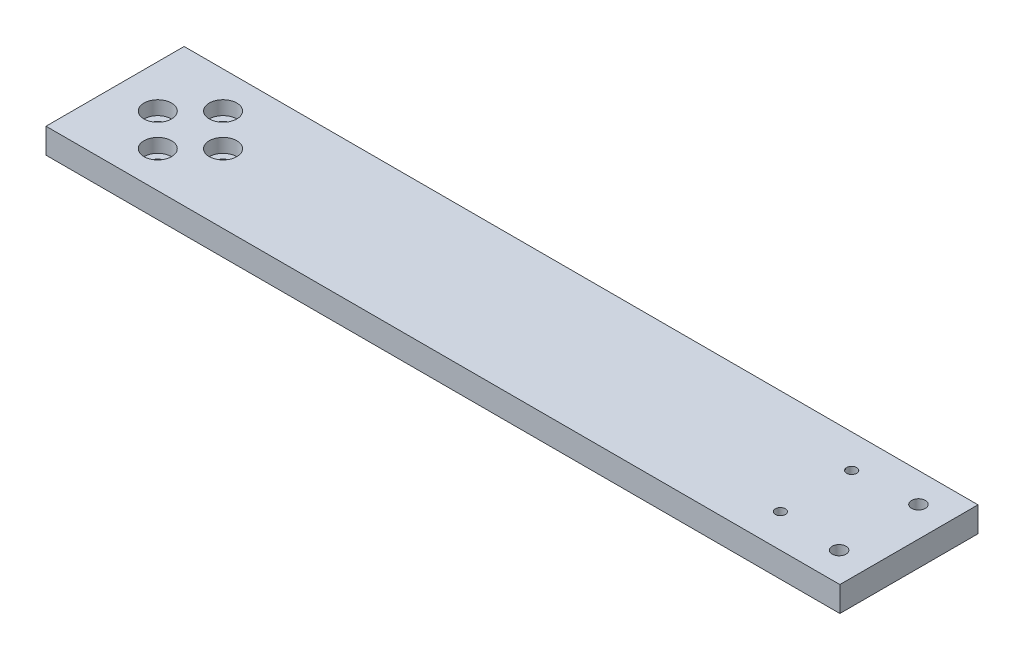
from build123d import *

# Parameters (mm, degrees)
SKETCH1_W           = 316.1
SKETCH1_H           = 55
BOSS_EXTRUDE1_DEPTH = 10
SKETCH2_R           = 2
SKETCH2_R_2         = 2.75
CUT_EXTRUDE1_DEPTH  = 11
SKETCH3_R           = 5.5
CUT_EXTRUDE2_DEPTH  = 5.5
SKETCH4_R           = 2.75
CUT_EXTRUDE3_DEPTH  = 11
SKETCH6_R           = 4.5
CUT_EXTRUDE4_DEPTH  = 1.1
SKETCH7_R           = 5.5
CUT_EXTRUDE5_DEPTH  = 5.5


with BuildPart() as part:
    # Sketch1 → Boss-Extrude1 (new body)
    with BuildSketch(Plane(origin=(0, 0, 0), x_dir=(1, 0, 0), z_dir=(0, 1, 0))):
        with Locations((158.05, 27.5)):
            Rectangle(SKETCH1_W, SKETCH1_H)
    extrude(amount=BOSS_EXTRUDE1_DEPTH)

    # Sketch2 → Cut-Extrude1 (cut, through all)
    with BuildSketch(Plane(origin=(0, 10, 0), x_dir=(1, 0, 0), z_dir=(0, 1, 0))):
        with Locations((279.1, 13.3)):
            Circle(SKETCH2_R)
        with Locations((279.1, 41.7)):
            Circle(SKETCH2_R)
        with Locations((304.1, 43.3)):
            Circle(SKETCH2_R_2)
        with Locations((304.1, 11.7)):
            Circle(SKETCH2_R_2)
    extrude(amount=-CUT_EXTRUDE1_DEPTH, mode=Mode.SUBTRACT)

    # Sketch3 → Cut-Extrude2 (cut)
    with BuildSketch(Plane.XZ):
        with Locations((304.1, -11.7)):
            Circle(SKETCH3_R)
        with Locations((304.1, -43.3)):
            Circle(SKETCH3_R)
    extrude(amount=-CUT_EXTRUDE2_DEPTH, mode=Mode.SUBTRACT)

    # Sketch4 → Cut-Extrude3 (cut, through all)
    with BuildSketch(Plane(origin=(0, 10, 0), x_dir=(1, 0, 0), z_dir=(0, 1, 0))):
        with Locations((17, 27.5)):
            Circle(SKETCH4_R)
        with Locations((30, 40.5)):
            Circle(SKETCH4_R)
        with Locations((43, 27.5)):
            Circle(SKETCH4_R)
        with Locations((30, 14.5)):
            Circle(SKETCH4_R)
    extrude(amount=-CUT_EXTRUDE3_DEPTH, mode=Mode.SUBTRACT)

    # Sketch6 → Cut-Extrude4 (cut)
    with BuildSketch(Plane.XZ):
        with Locations((30, -14.5)):
            Circle(SKETCH6_R)
        with Locations((30, -40.5)):
            Circle(SKETCH6_R)
    extrude(amount=-CUT_EXTRUDE4_DEPTH, mode=Mode.SUBTRACT)

    # Sketch7 → Cut-Extrude5 (cut)
    with BuildSketch(Plane(origin=(0, 10, 0), x_dir=(1, 0, 0), z_dir=(0, 1, 0))):
        with Locations((17, 27.5)):
            Circle(SKETCH7_R)
        with Locations((30, 40.5)):
            Circle(SKETCH7_R)
        with Locations((43, 27.5)):
            Circle(SKETCH7_R)
        with Locations((30, 14.5)):
            Circle(SKETCH7_R)
    extrude(amount=-CUT_EXTRUDE5_DEPTH, mode=Mode.SUBTRACT)


solid = part.part
